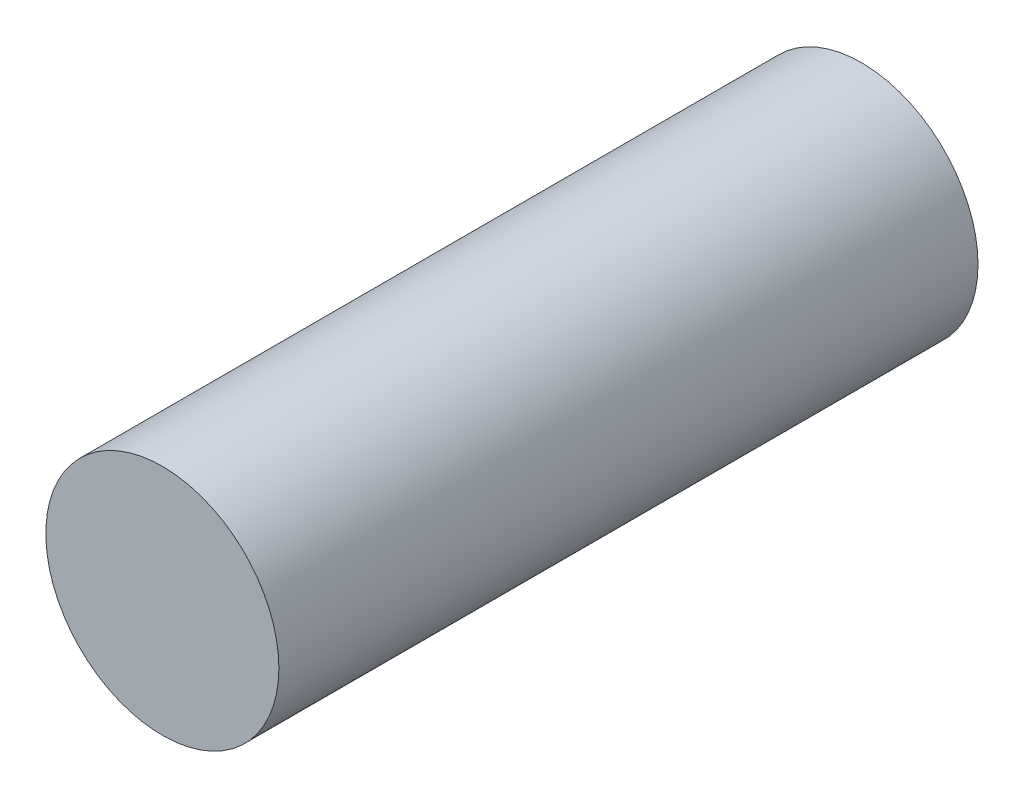
from build123d import *

# Parameters (mm, degrees)
SKETCH1_R           = 25.4
BOSS_EXTRUDE1_DEPTH = 152.4


with BuildPart() as part:
    # Sketch1 → Boss-Extrude1 (new body)
    with BuildSketch(Plane.XY):
        Circle(SKETCH1_R)
    extrude(amount=BOSS_EXTRUDE1_DEPTH)


solid = part.part
